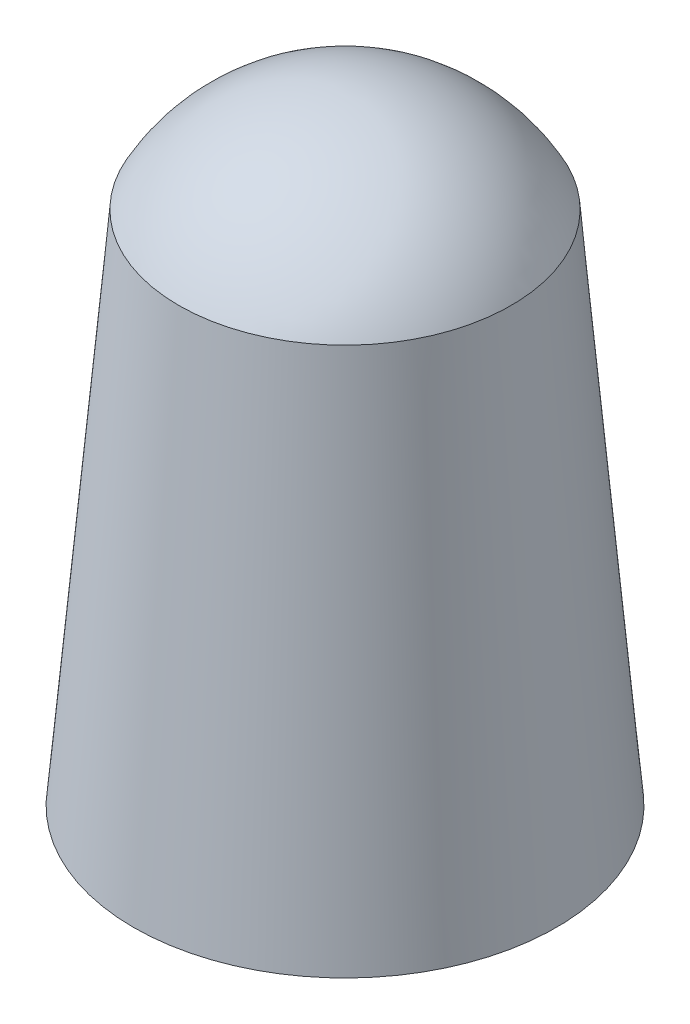
from build123d import *

# Parameters (mm, degrees)
SKETCH1_R           = 5.4102
BOSS_EXTRUDE1_DEPTH = 13.208
BOSS_EXTRUDE1_TAPER = 5
DOME1_FACE_RADIUS   = 4.254649732
DOME1_HEIGHT        = 2.54


with BuildPart() as part:
    # Sketch1 → Boss-Extrude1 (new body)
    with BuildSketch(Plane(origin=(0, 0, 0), x_dir=(1, 0, 0), z_dir=(0, 1, 0))):
        Circle(SKETCH1_R)
    extrude(amount=BOSS_EXTRUDE1_DEPTH, taper=BOSS_EXTRUDE1_TAPER)

    # Dome1: a dome of height H over a round flat face of radius A is a cap of a sphere of radius (A * A + H * H) / (2 * H)
    dome1_r = (DOME1_FACE_RADIUS * DOME1_FACE_RADIUS + DOME1_HEIGHT * DOME1_HEIGHT) / (2 * DOME1_HEIGHT)
    dome1_base = Plane((0, 13.208, 0), z_dir=(0, 1, 0))
    with Locations(dome1_base.offset(DOME1_HEIGHT - dome1_r)):
        dome1_ball = Sphere(dome1_r, mode=Mode.PRIVATE)
    add(split(dome1_ball, bisect_by=dome1_base, keep=Keep.TOP, mode=Mode.PRIVATE))


solid = part.part
